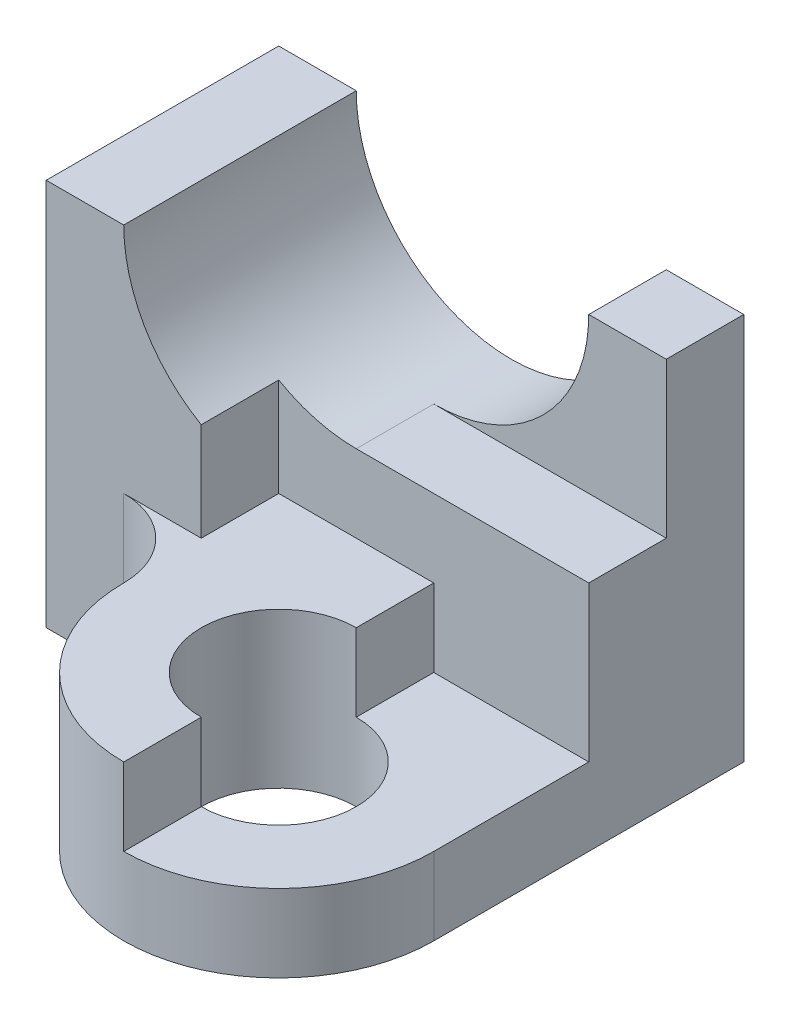
from build123d import *

# Parameters (mm, degrees)
BOSS_EXTRUDE1_DEPTH = 3
SKETCH2_W           = 2
SKETCH2_H           = 2
CUT_EXTRUDE14_DEPTH = 2
SKETCH6_W           = 1
SKETCH6_H           = 3.267949192
CUT_EXTRUDE16_DEPTH = 4
CUT_EXTRUDE17_DEPTH = 1
SKETCH9_R           = 1
BOSS_EXTRUDE2_DEPTH = 2
CUT_EXTRUDE18_DEPTH = 1


with BuildPart() as part:
    # Sketch1 → Boss-Extrude1 (new body)
    with BuildSketch(Plane.XY):
        with BuildLine():
            Line((-2, 0), (-3, 0))
            Line((-3, 0), (-3, -5))
            Line((-3, -5), (3, -5))
            Line((3, -5), (3, 0))
            Line((3, 0), (2, 0))
            ThreePointArc((2, 0), (0, -2), (-2, 0))
        make_face()
    extrude(amount=BOSS_EXTRUDE1_DEPTH)

    # Sketch2 → Cut-Extrude14 (cut)
    with BuildSketch(Plane(origin=(0, 0, 0), x_dir=(1, 0, 0), z_dir=(0, 1, 0))):
        with Locations((2, -2)):
            Rectangle(SKETCH2_W, SKETCH2_H)
    extrude(amount=-CUT_EXTRUDE14_DEPTH, mode=Mode.SUBTRACT)

    # Sketch6 → Cut-Extrude16 (cut)
    with BuildSketch(Plane(origin=(3, 0, 0), x_dir=(0, 0, -1), z_dir=(1, 0, 0))):
        with Locations((-2.5, -3.366025404)):
            Rectangle(SKETCH6_W, SKETCH6_H)
    extrude(amount=-CUT_EXTRUDE16_DEPTH, mode=Mode.SUBTRACT)

    # Sketch8 → Cut-Extrude17 (cut)
    with BuildSketch(Plane.XY.offset(2)):
        with BuildLine():
            Line((1, -2), (0, -2))
            ThreePointArc((0, -2), (0.51763809, -1.931851653), (1, -1.732050808))
            Line((1, -1.732050808), (1, -2))
        make_face()
    extrude(amount=-CUT_EXTRUDE17_DEPTH, mode=Mode.SUBTRACT)

    # Sketch9 → Boss-Extrude2 (add)
    with BuildSketch(Plane.XZ.offset(5)):
        with BuildLine():
            Line((3, 2), (3, 4))
            ThreePointArc((3, 4), (1, 6), (-1, 4))
            ThreePointArc((-1, 4), (-1.292893219, 3.292893219), (-2, 3))
            Line((-2, 3), (-1, 3))
            Line((-1, 3), (-1, 2))
            Line((-1, 2), (3, 2))
        make_face()
        with Locations((1, 4)):
            Circle(SKETCH9_R, mode=Mode.SUBTRACT)
    extrude(amount=-BOSS_EXTRUDE2_DEPTH)

    # Sketch10 → Cut-Extrude18 (cut)
    with BuildSketch(Plane(origin=(0, -3, 0), x_dir=(1, 0, 0), z_dir=(0, 1, 0))):
        with BuildLine():
            Line((1, -2), (1, -6))
            ThreePointArc((1, -6), (2.414213562, -5.414213562), (3, -4))
            Line((3, -4), (3, -2))
            Line((3, -2), (1, -2))
        make_face()
    extrude(amount=-CUT_EXTRUDE18_DEPTH, mode=Mode.SUBTRACT)


solid = part.part
